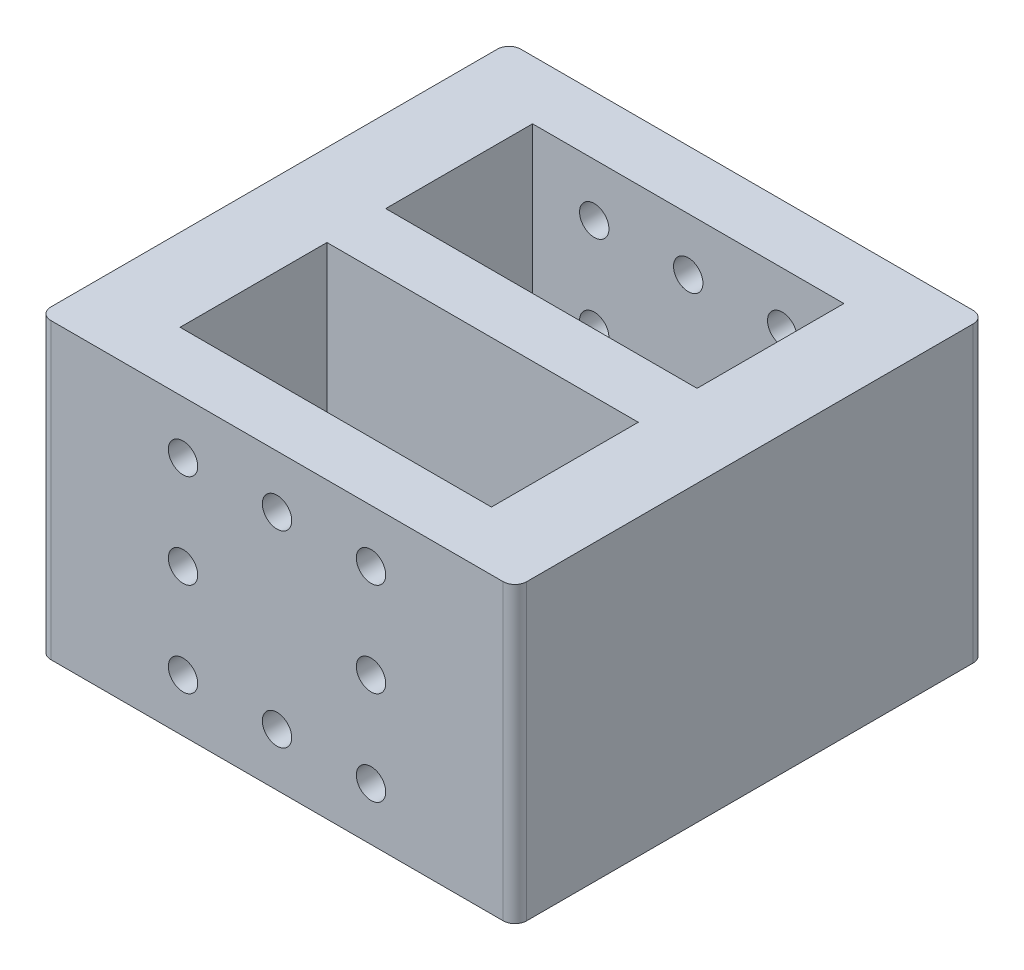
from build123d import *

# Parameters (mm, degrees)
SKETCH1_W               = 40.5
SKETCH1_H               = 25
BOSS_EXTRUDE1_DEPTH     = 40
CUT_EXTRUDE1_START      = -5
SKETCH2_W               = 26.5
SKETCH2_H               = 25
CUT_EXTRUDE1_DEPTH      = 30
FILLET1_R               = 1
SKETCH3_R               = 1.25
CUT_EXTRUDE2_DEPTH      = 35
CUT_EXTRUDE2_DEPTH_BACK = 5
FILLET2_R               = 1
SKETCH6_W               = 5
SKETCH6_H               = 25
BOSS_EXTRUDE3_DEPTH     = 40.5


with BuildPart() as part:
    # Sketch1 → Boss-Extrude1 (new body)
    with BuildSketch(Plane.XY):
        with Locations((20.25, 12.5)):
            Rectangle(SKETCH1_W, SKETCH1_H)
    extrude(amount=BOSS_EXTRUDE1_DEPTH)

    # Sketch2 → Cut-Extrude1 (cut)
    with BuildSketch(Plane.XY.offset(40).offset(CUT_EXTRUDE1_START)):
        with Locations((20.25, 12.5)):
            Rectangle(SKETCH2_W, SKETCH2_H)
    extrude(amount=-CUT_EXTRUDE1_DEPTH, mode=Mode.SUBTRACT)

    # Fillet1
    fillet1_edges = [part.edges().sort_by_distance(p)[0] for p in [
        (40.5, 12.5, 0),
        (0, 12.5, 0),
    ]]
    fillet(fillet1_edges, radius=FILLET1_R)

    # Sketch3 → Cut-Extrude2 (cut, two sides)
    with BuildSketch(Plane.XY.offset(5)) as cut_extrude2_sk:
        with Locations((12.25, 4.5)):
            Circle(SKETCH3_R)
        with Locations((20.25, 4.5)):
            Circle(SKETCH3_R)
        with Locations((12.25, 12.5)):
            Circle(SKETCH3_R)
        with Locations((12.25, 20.5)):
            Circle(SKETCH3_R)
        with Locations((20.25, 20.5)):
            Circle(SKETCH3_R)
        with Locations((28.25, 4.5)):
            Circle(SKETCH3_R)
        with Locations((28.25, 12.5)):
            Circle(SKETCH3_R)
        with Locations((28.25, 20.5)):
            Circle(SKETCH3_R)
    extrude(amount=CUT_EXTRUDE2_DEPTH, mode=Mode.SUBTRACT)
    extrude(cut_extrude2_sk.sketch, amount=-CUT_EXTRUDE2_DEPTH_BACK, mode=Mode.SUBTRACT)

    # Fillet2
    fillet2_edges = [part.edges().sort_by_distance(p)[0] for p in [
        (40.5, 12.5, 40),
        (0, 12.5, 40),
    ]]
    fillet(fillet2_edges, radius=FILLET2_R)

    # Sketch6 → Boss-Extrude3 (add)
    with BuildSketch(Plane(origin=(40.5, 0, 0), x_dir=(0, 0, -1), z_dir=(1, 0, 0))):
        with Locations((-20, 12.5)):
            Rectangle(SKETCH6_W, SKETCH6_H)
    extrude(amount=-BOSS_EXTRUDE3_DEPTH)


solid = part.part
